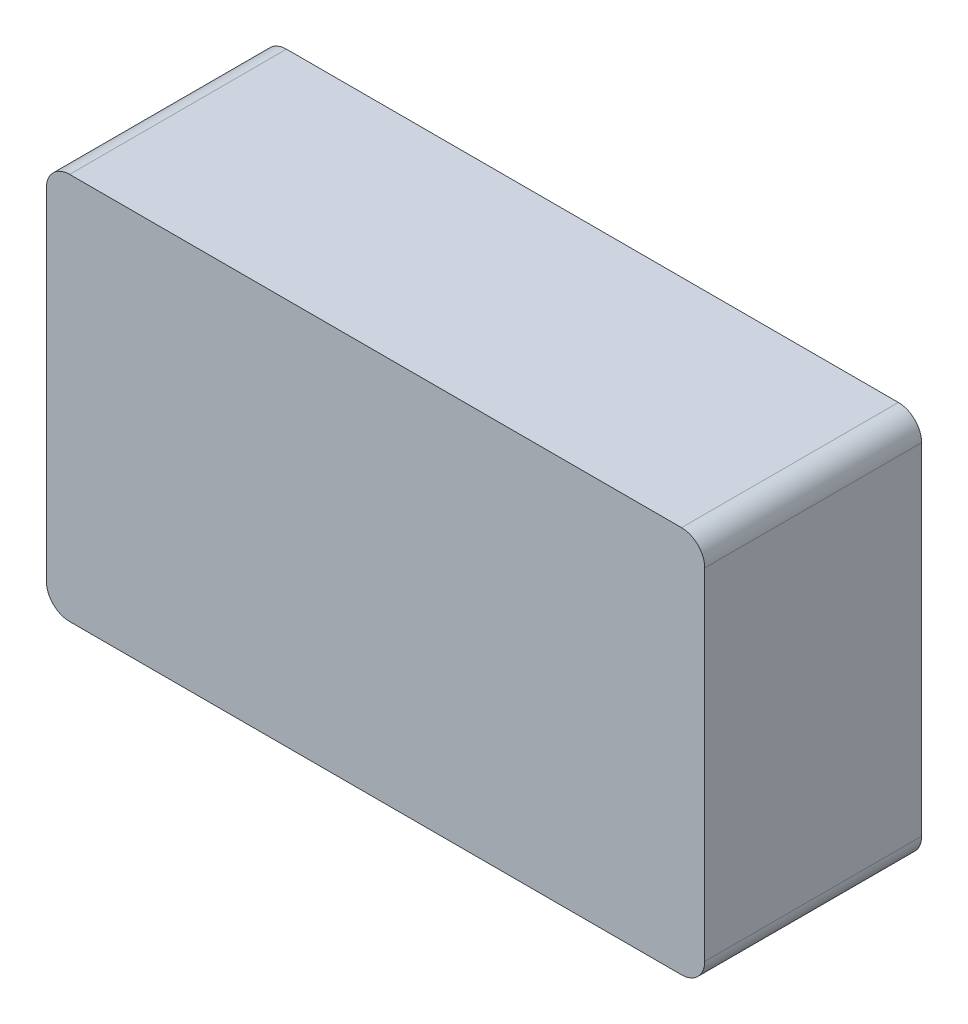
from build123d import *

# Parameters (mm, degrees)
ESQUISSE1_W        = 85
ESQUISSE1_H        = 50
BOSS_EXTRU_1_DEPTH = 28
CONG_1_R           = 3


with BuildPart() as part:
    # Esquisse1 → Boss.-Extru.1 (new body)
    with BuildSketch(Plane.XY):
        with Locations((42.5, -25)):
            Rectangle(ESQUISSE1_W, ESQUISSE1_H)
    extrude(amount=BOSS_EXTRU_1_DEPTH)

    # Congé1
    cong_1_edges = [part.edges().sort_by_distance(p)[0] for p in [
        (0, 0, 14),
        (85, 0, 14),
        (85, -50, 14),
        (0, -50, 14),
    ]]
    fillet(cong_1_edges, radius=CONG_1_R)


solid = part.part
